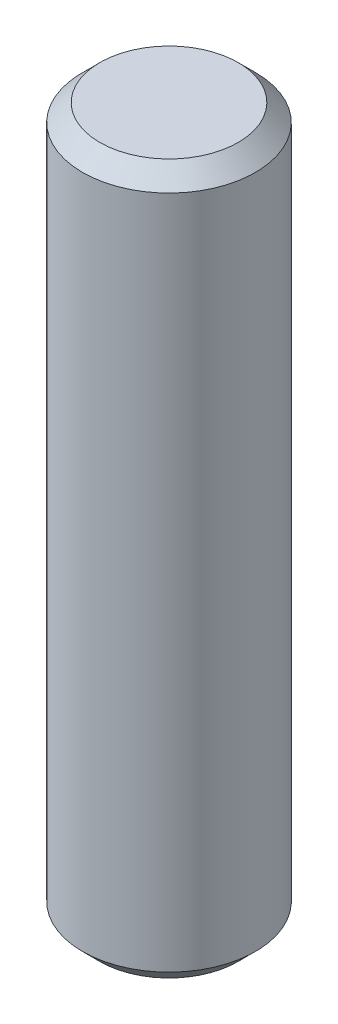
from build123d import *


with BuildPart() as part:
    # Эскиз1 → Повернуть1 (revolve)
    with BuildSketch(Plane.XY):
        Polygon((0, 0), (0, 41), (4, 41), (5, 40), (5, 1), (4, 0), align=None)
    revolve(axis=Axis((0, 0, 0), (0, -1, 0)))


solid = part.part
